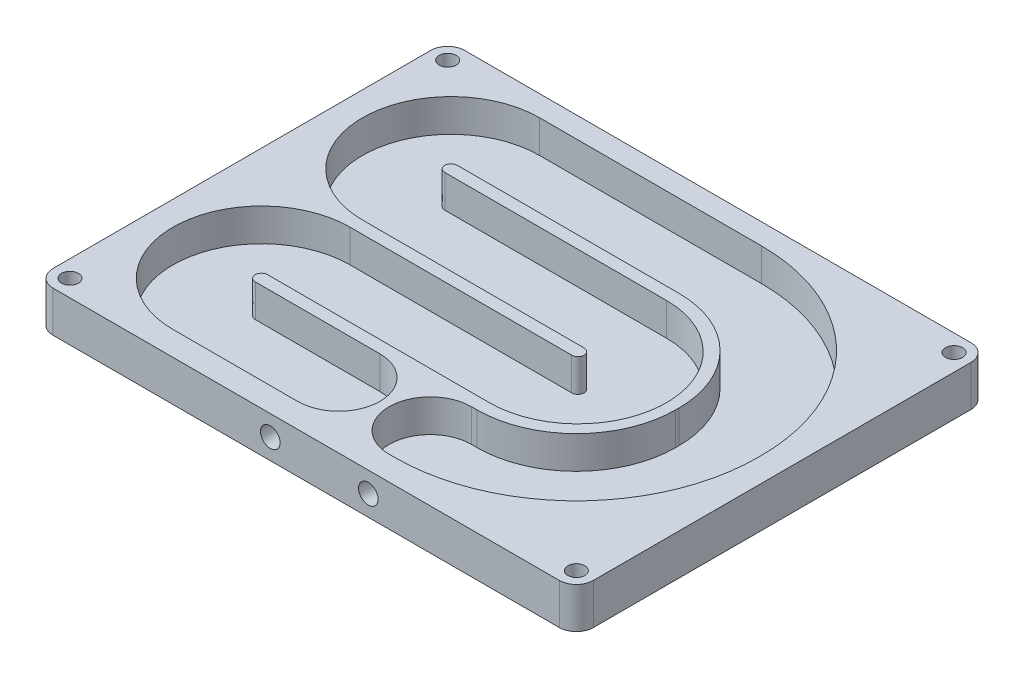
from build123d import *

# Parameters (mm, degrees)
SKETCH1_R           = 3.302
BOSS_EXTRUDE1_DEPTH = 15.875
CUT_EXTRUDE1_DEPTH  = 12.7
SKETCH4_R           = 3.81
CUT_EXTRUDE2_DEPTH  = 13.97


with BuildPart() as part:
    # Sketch1 → Boss-Extrude1 (new body)
    with BuildSketch(Plane(origin=(0, 0, 0), x_dir=(1, 0, 0), z_dir=(0, 1, 0))):
        with BuildLine():
            Line((-98.396, 0), (98.396, 0))
            ThreePointArc((98.396, 0), (103.065733183, 1.934266817), (105, 6.604))
            Line((105, 6.604), (105, 153.396))
            ThreePointArc((105, 153.396), (103.065733183, 158.065733183), (98.396, 160))
            Line((98.396, 160), (-98.396, 160))
            ThreePointArc((-98.396, 160), (-103.065733183, 158.065733183), (-105, 153.396))
            Line((-105, 153.396), (-105, 6.604))
            ThreePointArc((-105, 6.604), (-103.065733183, 1.934266817), (-98.396, 0))
        make_face()
        with Locations(Location((-98.396, 6.604, 0), (0, 0, 270))):  # turned: the seam where the file's is
            Circle(SKETCH1_R, mode=Mode.SUBTRACT)
        with Locations(Location((98.396, 6.604, 0), (0, 0, 270))):  # turned: the seam where the file's is
            Circle(SKETCH1_R, mode=Mode.SUBTRACT)
        with Locations(Location((98.396, 153.396, 0), (0, 0, 270))):  # turned: the seam where the file's is
            Circle(SKETCH1_R, mode=Mode.SUBTRACT)
        with Locations(Location((-98.396, 153.396, 0), (0, 0, 270))):  # turned: the seam where the file's is
            Circle(SKETCH1_R, mode=Mode.SUBTRACT)
    extrude(amount=BOSS_EXTRUDE1_DEPTH)

    # Sketch3 → Cut-Extrude1 (cut)
    with BuildSketch(Plane(origin=(0, 15.875, 0), x_dir=(1, 0, 0), z_dir=(0, 1, 0))):
        with BuildLine():
            Line((63.598, 80.01), (63.598, 81.28))
            ThreePointArc((63.598, 81.28), (52.289978608, 108.579978608), (24.99, 119.888))
            Line((24.99, 119.888), (-61.185, 119.888))
            ThreePointArc((-61.185, 119.888), (-63.598, 117.475), (-61.185, 115.062))
            Line((-61.185, 115.062), (24.99, 115.062))
            ThreePointArc((24.99, 115.062), (59.407, 80.645), (24.99, 46.228))
            Line((24.99, 46.228), (-61.185, 46.228))
            ThreePointArc((-61.185, 46.228), (-63.598, 43.815), (-61.185, 41.402))
            Line((-61.185, 41.402), (-12.729, 41.402))
            ThreePointArc((-12.729, 41.402), (3.273, 25.4), (-12.729, 9.398))
            Line((-12.729, 9.398), (-61.185, 9.398))
            ThreePointArc((-61.185, 9.398), (-95.602, 43.815), (-61.185, 78.232))
            Line((-61.185, 78.232), (24.99, 78.232))
            ThreePointArc((24.99, 78.232), (27.403, 80.645), (24.99, 83.058))
            Line((24.99, 83.058), (-61.185, 83.058))
            ThreePointArc((-61.185, 83.058), (-95.602, 117.475), (-61.185, 151.892))
            Line((-61.185, 151.892), (24.99, 151.892))
            ThreePointArc((24.99, 151.892), (74.920224033, 131.210224033), (95.602, 81.28))
            Line((95.602, 81.28), (95.602, 80.01))
            ThreePointArc((95.602, 80.01), (74.920224033, 30.079775967), (24.99, 9.398))
            Line((24.99, 9.398), (22.831, 9.398))
            ThreePointArc((22.831, 9.398), (6.829, 25.4), (22.831, 41.402))
            Line((22.831, 41.402), (24.99, 41.402))
            ThreePointArc((24.99, 41.402), (52.289978608, 52.710021392), (63.598, 80.01))
        make_face()
    extrude(amount=-CUT_EXTRUDE1_DEPTH, mode=Mode.SUBTRACT)

    # Sketch4 → Cut-Extrude2 (cut)
    with BuildSketch(Plane.XY):
        with Locations((-13.941, 7.9375)):
            Circle(SKETCH4_R)
        with Locations((24.159, 7.9375)):
            Circle(SKETCH4_R)
    extrude(amount=-CUT_EXTRUDE2_DEPTH, mode=Mode.SUBTRACT)


solid = part.part
